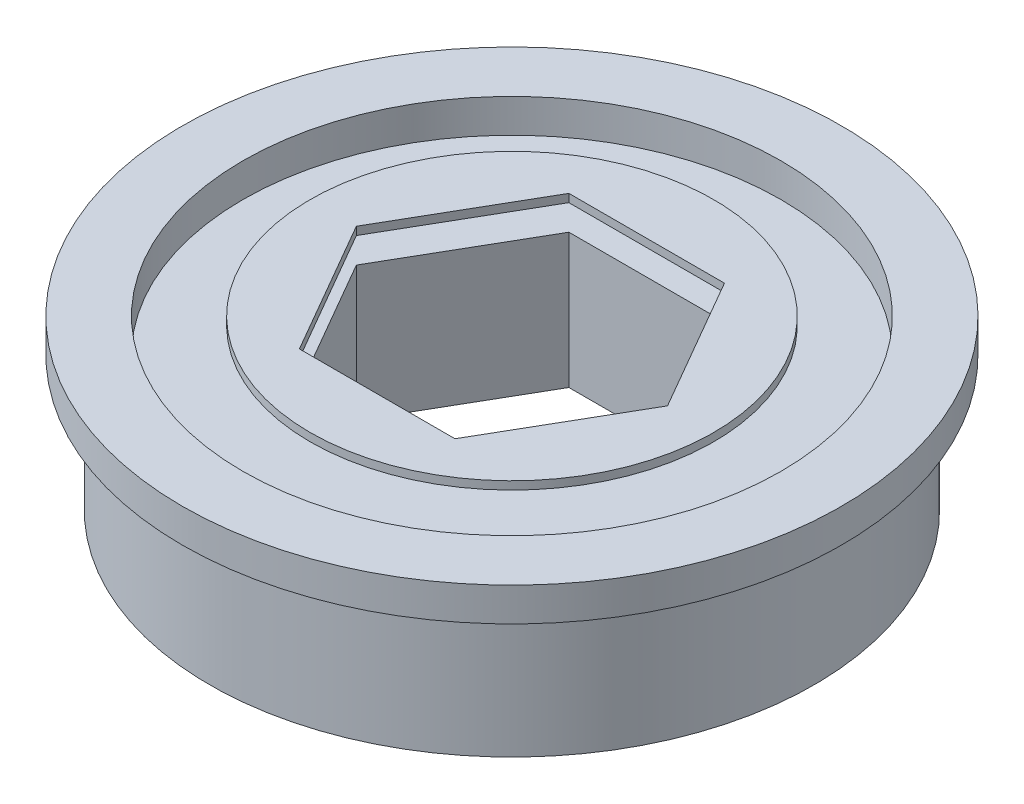
from build123d import *

# Parameters (mm, degrees)
SKETCH1_W                  = 15.5575
SKETCH1_H                  = 1.5875
F_1_1_DIAMETER_HOLE1_D     = 25.4
F_1_1_DIAMETER_HOLE1_DEPTH = 1.5875
SKETCH4_R                  = 9.525
BOSS_EXTRUDE1_DEPTH        = 0.381
SKETCH5_R                  = 14.2748
BOSS_EXTRUDE2_DEPTH        = 6.35
CUT_EXTRUDE1_DEPTH         = 8.9375


with BuildPart() as part:
    # Sketch1 → Revolve1 (revolve)
    with BuildSketch(Plane(origin=(0, 0, 0), x_dir=(-1, 0, 0), z_dir=(0, 0, -1))):
        with Locations((-7.77875, 7.14375)):
            Rectangle(SKETCH1_W, SKETCH1_H)
    revolve(axis=Axis((0, 6.35, 0), (0, 1, 0)))

    # 1 (1) Diameter Hole1
    with Locations(Plane(origin=(0, 7.9375, 0), x_dir=(1, 0, 0), z_dir=(0, 1, 0))):
        with Locations((0, 0)):
            Hole(F_1_1_DIAMETER_HOLE1_D / 2, depth=F_1_1_DIAMETER_HOLE1_DEPTH)

    # Sketch5 → Boss-Extrude2 (add)
    with BuildSketch(Plane.XZ.offset(-6.35)):
        Circle(SKETCH5_R)
    extrude(amount=BOSS_EXTRUDE2_DEPTH)


with BuildPart() as body_2:
    # Sketch4 → Boss-Extrude1 (new body)
    with BuildSketch(Plane.XZ.offset(-7.5565)):
        Circle(SKETCH4_R)
    extrude(amount=-BOSS_EXTRUDE1_DEPTH)


with BuildPart() as cut_extrude1_tool:
    # Sketch6 → Cut-Extrude1 (new body, through all)
    with BuildSketch(Plane.XZ):
        Polygon((-3.671947712, 6.36), (-7.343895424, 0), (-3.671947712, -6.36), (3.671947712, -6.36), (7.343895424, 0), (3.671947712, 6.36), align=None)
    extrude(amount=-CUT_EXTRUDE1_DEPTH)


with BuildPart() as part_1:
    add(part.part)

    # Cut-Extrude1: cut by cut_extrude1_tool
    add(cut_extrude1_tool.part, mode=Mode.SUBTRACT)


with BuildPart() as body_2_1:
    add(body_2.part)

    # Cut-Extrude1: cut by cut_extrude1_tool
    add(cut_extrude1_tool.part, mode=Mode.SUBTRACT)


solid = Compound([part_1.part, body_2_1.part])
